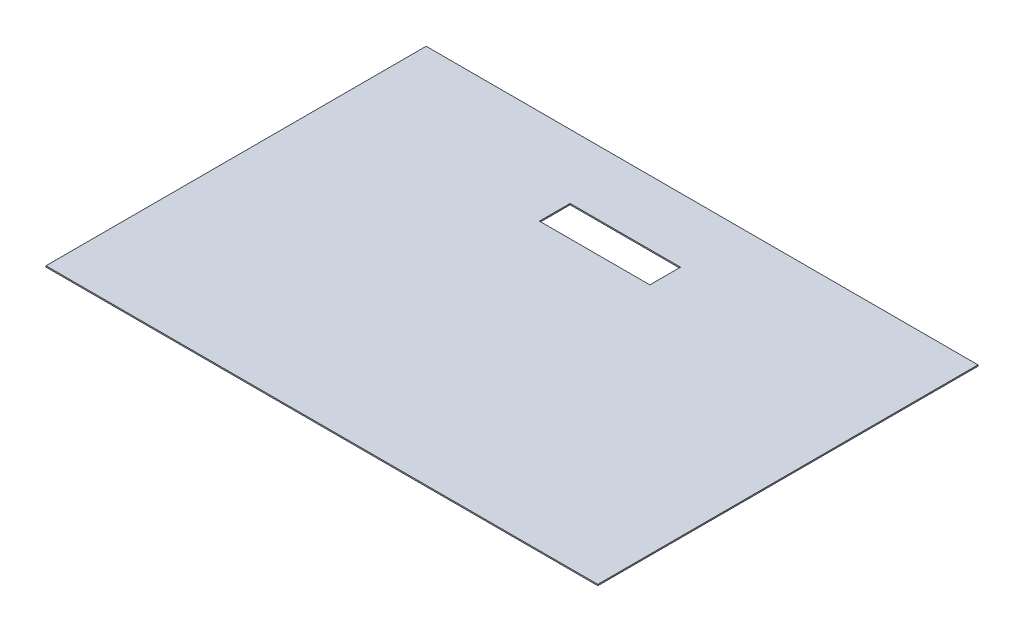
from build123d import *

# Parameters (mm, degrees)
SKETCH2_W           = 450
SKETCH2_H           = 310
SKETCH2_W_2         = 90
SKETCH2_H_2         = 25
BOSS_EXTRUDE1_DEPTH = 1


with BuildPart() as part:
    # Sketch2 → Boss-Extrude1 (new body)
    with BuildSketch(Plane(origin=(0, 0, 0), x_dir=(1, 0, 0), z_dir=(0, 1, 0))):
        Rectangle(SKETCH2_W, SKETCH2_H)
        with Locations((-10.291059401, 90.2)):
            Rectangle(SKETCH2_W_2, SKETCH2_H_2, mode=Mode.SUBTRACT)
    extrude(amount=BOSS_EXTRUDE1_DEPTH)


solid = part.part
